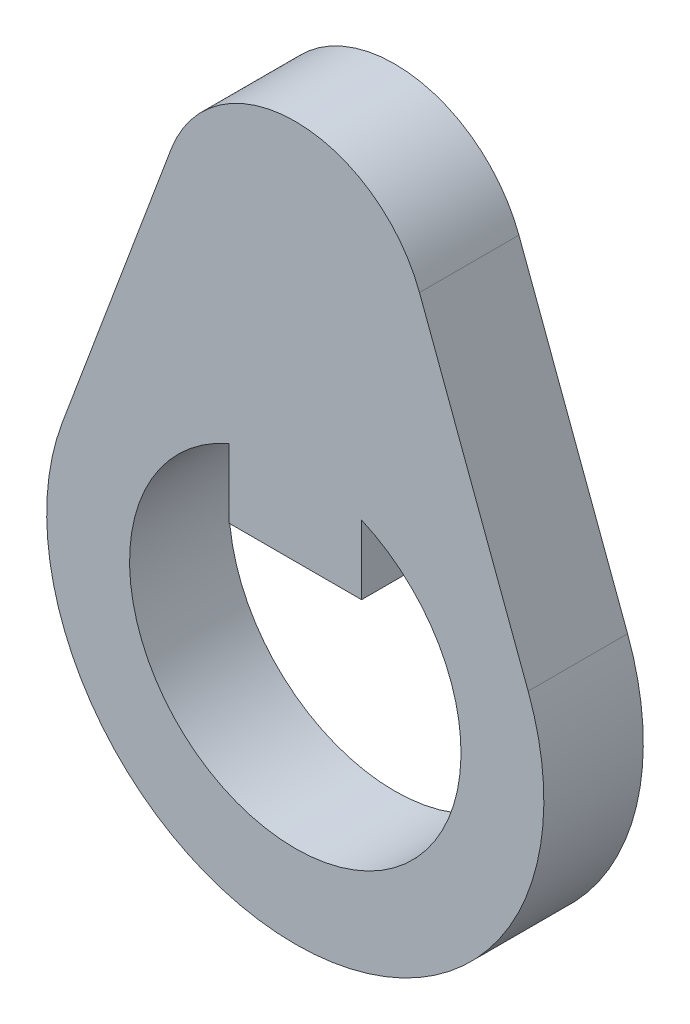
from build123d import *

# Parameters (mm, degrees)
BOSS_EXTRUDE1_DEPTH = 6


with BuildPart() as part:
    # Sketch1 → Boss-Extrude1 (new body)
    with BuildSketch(Plane.XY):
        with BuildLine():
            ThreePointArc((7.493997598, 22.8), (0, 28), (-7.493997598, 22.8))
            Line((-7.493997598, 22.8), (-14.051245496, 5.25))
            ThreePointArc((-14.051245496, 5.25), (0, -15), (14.051245496, 5.25))
            Line((14.051245496, 5.25), (7.493997598, 22.8))
        make_face()
        with BuildLine():
            Line((-4, 9.16515139), (-4, 5))
            Line((-4, 5), (4, 5))
            Line((4, 5), (4, 9.16515139))
            ThreePointArc((4, 9.16515139), (0, -10), (-4, 9.16515139))
        make_face(mode=Mode.SUBTRACT)
    extrude(amount=BOSS_EXTRUDE1_DEPTH)


solid = part.part
